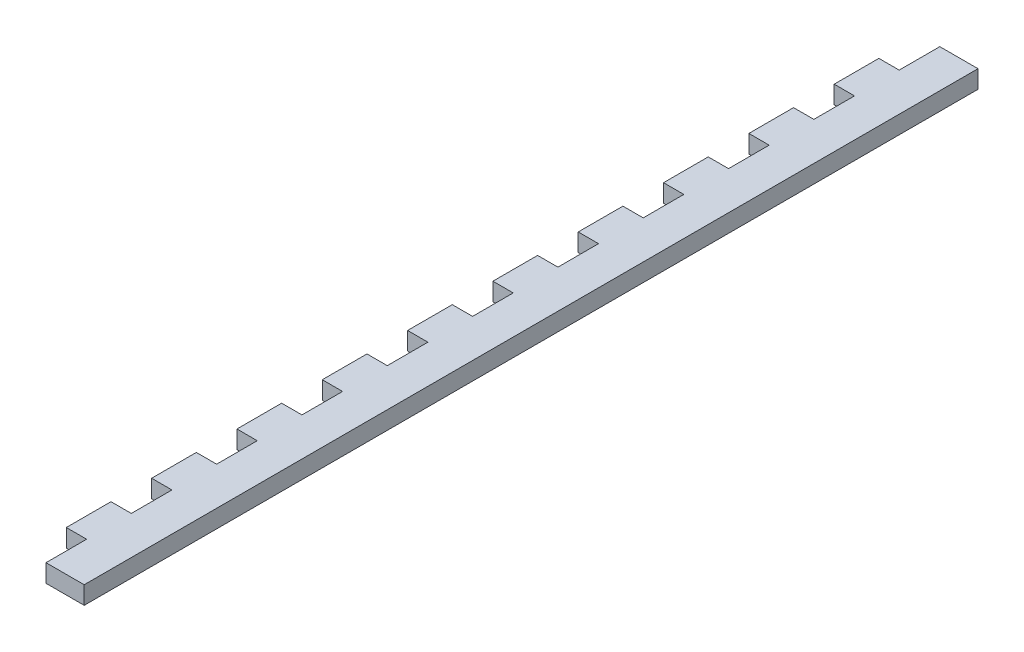
from build123d import *

# Parameters (mm, degrees)
SKETCH1_W           = 279.4
SKETCH1_H           = 285.75
BOSS_EXTRUDE1_DEPTH = 5.588
SKETCH2_W           = 279.4
SKETCH2_H           = 5.588
BOSS_EXTRUDE2_DEPTH = 12.7
CUT_EXTRUDE1_DEPTH  = 19.288
SKETCH5_W           = 64.162912319
SKETCH5_H           = 368.728813298
CUT_EXTRUDE2_DEPTH  = 280.4
SKETCH4_W           = 12.7
SKETCH4_H           = 5.588
CUT_EXTRUDE3_DEPTH  = 6.35


with BuildPart() as part:
    # Sketch1 → Boss-Extrude1 (new body)
    with BuildSketch(Plane(origin=(0, 0, 0), x_dir=(0, 0, -1), z_dir=(1, 0, 0))):
        Rectangle(SKETCH1_W, SKETCH1_H)
    extrude(amount=BOSS_EXTRUDE1_DEPTH)

    # Sketch2 → Boss-Extrude2 (add)
    with BuildSketch(Plane(origin=(5.588, 0, 0), x_dir=(0, 0, -1), z_dir=(1, 0, 0))):
        with Locations((0, 140.081)):
            Rectangle(SKETCH2_W, SKETCH2_H)
    extrude(amount=BOSS_EXTRUDE2_DEPTH)

    # Sketch3 → Cut-Extrude1 (cut, through all)
    with BuildSketch(Plane.ZY):
        with BuildLine():
            Line((-114.3, -85.725), (-25.4, -85.725))
            ThreePointArc((-25.4, -85.725), (-12.7, -98.425), (-25.4, -111.125))
            Line((-25.4, -111.125), (-114.3, -111.125))
            ThreePointArc((-114.3, -111.125), (-127, -98.425), (-114.3, -85.725))
        make_face()
    extrude(amount=-CUT_EXTRUDE1_DEPTH, mode=Mode.SUBTRACT)

    # Sketch5 → Cut-Extrude2 (cut, through all)
    with BuildSketch(Plane(origin=(0, 0, -139.7), x_dir=(-1, 0, 0), z_dir=(0, 0, -1))):
        with Locations((13.79345616, -47.077406649)):
            Rectangle(SKETCH5_W, SKETCH5_H)
    extrude(amount=-CUT_EXTRUDE2_DEPTH, mode=Mode.SUBTRACT)

    # Sketch4 → Cut-Extrude3 (cut)
    with BuildSketch(Plane.ZY):
        with Locations((-106.68, 140.081)):
            Rectangle(SKETCH4_W, SKETCH4_H)
        with Locations((-133.35, 140.081)):
            Rectangle(SKETCH4_W, SKETCH4_H)
        with Locations((-80.01, 140.081)):
            Rectangle(SKETCH4_W, SKETCH4_H)
        with Locations((-53.34, 140.081)):
            Rectangle(SKETCH4_W, SKETCH4_H)
        with Locations((-26.67, 140.081)):
            Rectangle(SKETCH4_W, SKETCH4_H)
        with Locations((0, 140.081)):
            Rectangle(SKETCH4_W, SKETCH4_H)
        with Locations((26.67, 140.081)):
            Rectangle(SKETCH4_W, SKETCH4_H)
        with Locations((53.34, 140.081)):
            Rectangle(SKETCH4_W, SKETCH4_H)
        with Locations((80.01, 140.081)):
            Rectangle(SKETCH4_W, SKETCH4_H)
        with Locations((106.68, 140.081)):
            Rectangle(SKETCH4_W, SKETCH4_H)
        with Locations((133.35, 140.081)):
            Rectangle(SKETCH4_W, SKETCH4_H)
    extrude(amount=-CUT_EXTRUDE3_DEPTH, mode=Mode.SUBTRACT)


solid = part.part
